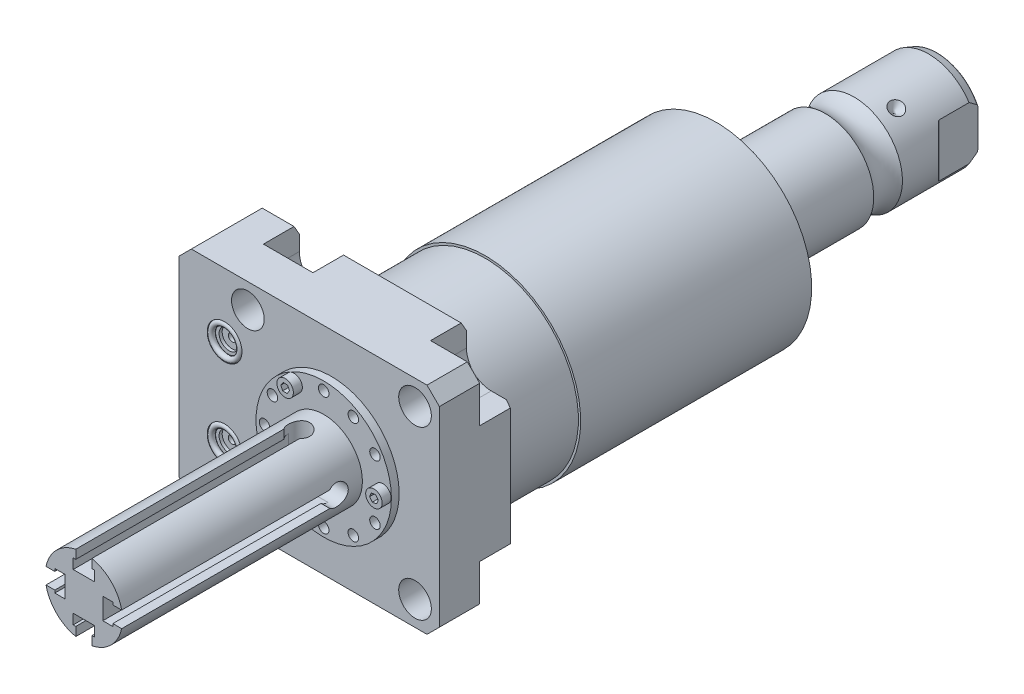
from build123d import *

# Parameters (mm, degrees)
SKETCH1_W                   = 85.4964
SKETCH1_H                   = 70.866
EXTRUDE1_DEPTH              = 25.019
SKETCH2_R                   = 5.3594
CUT_EXTRUDE1_DEPTH          = 27.5209
LPATTERN1_COUNT             = 2
LPATTERN1_PITCH             = 54.864
LPATTERN1_COUNT_DIR2        = 2
LPATTERN1_PITCH_DIR2        = 54.864
CUT_EXTRUDE2_DEPTH          = 11.7856
SKETCH6_R                   = 5.7023
CUT_EXTRUDE3_DEPTH          = 1.4478
SKETCH7_R                   = 3.2512
CUT_EXTRUDE4_DEPTH          = 1.016
SKETCH8_R                   = 1.2446
CUT_EXTRUDE5_DEPTH          = 11.9888
SKETCH9_R                   = 0.9271
CHAMFER1_SIZE               = 4.064
CHAMFER2_SIZE               = 3.0226
CHAMFER2_SIZE2              = 1.745099
SKETCH14_R                  = 31.3944
EXTRUDE2_DEPTH              = 104.5464
SKETCH15_OUTSIDE_W          = 121.686
SKETCH15_OUTSIDE_H          = 107.056
SKETCH15_OUTSIDE_R          = 30.6578
CUT_EXTRUDE9_DEPTH          = 25.4
CIRPATTERN1_COUNT           = 3
FILLET1_R                   = 0.635
CUT_EXTRUDE12_DEPTH         = 36.433
CUT_EXTRUDE12_DEPTH_BACK    = 36.433
SKETCH28_R                  = 1.7272
CUT_EXTRUDE13_DEPTH         = 2.54
SKETCH29_R                  = 2.7051
EXTRUDE3_DEPTH              = 2.9464
CUT_EXTRUDE14_DEPTH         = 2.032
CUT_EXTRUDE15_DEPTH         = 6.477
SKETCH32_W                  = 6.985
SKETCH32_H                  = 70.612
CUT_EXTRUDE16_DEPTH         = 3.302
CIRPATTERN2_COUNT           = 2
CIRPATTERN2_ANGLE           = 90
CIRPATTERN2_COPY_1_DEPTH    = 6.477
CIRPATTERN2_COPY_2_SKETCH_W = 6.985
CIRPATTERN2_COPY_2_SKETCH_H = 70.612
CIRPATTERN2_COPY_2_DEPTH    = 3.302


with BuildPart() as part:
    # Sketch1 → Extrude1 (new body)
    with BuildSketch(Plane.XY):
        with Locations((-7.3152, 0)):
            Rectangle(SKETCH1_W, SKETCH1_H)
    extrude(amount=EXTRUDE1_DEPTH)

    # Sketch2 → Cut-Extrude1 (cut)
    with BuildSketch(Plane(origin=(0, 0, 0), x_dir=(-1, 0, 0), z_dir=(0, 0, -1))):
        with Locations((-27.432, -27.432)):
            Circle(SKETCH2_R)
    cut_extrude1 = extrude(amount=-CUT_EXTRUDE1_DEPTH, mode=Mode.SUBTRACT)

    # LPattern1: Cut-Extrude1 2 × 2
    with Locations(*[(-j * LPATTERN1_PITCH_DIR2, i * LPATTERN1_PITCH, 0) for i in range(LPATTERN1_COUNT) for j in range(LPATTERN1_COUNT_DIR2) if (i, j) != (0, 0)]):
        add(cut_extrude1, mode=Mode.SUBTRACT)

    # Sketch3 → Cut-Extrude2 (cut)
    with BuildSketch(Plane(origin=(0, 0, 0), x_dir=(-1, 0, 0), z_dir=(0, 0, -1))):
        with BuildLine():
            Line((-27.432, -19.304), (-35.433, -19.304))
            Line((-35.433, -19.304), (-35.433, -35.433))
            Line((-35.433, -35.433), (-19.304, -35.433))
            Line((-19.304, -35.433), (-19.304, -27.432))
            ThreePointArc((-19.304, -27.432), (-21.684636, -21.684636), (-27.432, -19.304))
        make_face()
        with BuildLine():
            Line((-35.433, 19.304), (-35.433, 35.433))
            Line((-35.433, 35.433), (-19.304, 35.433))
            Line((-19.304, 35.433), (-19.304, 27.432))
            ThreePointArc((-19.304, 27.432), (-21.684636, 21.684636), (-27.432, 19.304))
            Line((-27.432, 19.304), (-35.433, 19.304))
        make_face()
        with BuildLine():
            Line((19.304, 35.433), (19.304, 27.432))
            ThreePointArc((19.304, 27.432), (27.432, 19.304), (35.56, 27.432))
            Line((35.56, 27.432), (35.56, 35.433))
            Line((35.56, 35.433), (19.304, 35.433))
        make_face()
        with BuildLine():
            Line((35.56, -35.433), (19.304, -35.433))
            Line((19.304, -35.433), (19.304, -27.432))
            ThreePointArc((19.304, -27.432), (27.432, -19.304), (35.56, -27.432))
            Line((35.56, -27.432), (35.56, -35.433))
        make_face()
    extrude(amount=-CUT_EXTRUDE2_DEPTH, mode=Mode.SUBTRACT)

    # S2D0007 → Cut-Revolve1 (revolve, cut)
    with BuildSketch(Plane(origin=(-55.5498, -13.0048, 12.5222), x_dir=(0, 1, 0), z_dir=(0, 0, 1)), mode=Mode.PRIVATE) as cut_revolve1_sk:
        Polygon((0, -5.4864), (10.4775, -5.4864), (10.4775, -5.7404), (6.1849, -5.7404), (5.642307, -8.2931), (4.9784, -8.957007), (4.9784, -19.7104), (0, -19.7104), align=None)
    cut_revolve1 = revolve(cut_revolve1_sk.sketch.rotate(Axis((-35.077219, -13.0048, 12.5222), (-1, 0, 0)), 90), axis=Axis((-35.077219, -13.0048, 12.5222), (-1, 0, 0)), mode=Mode.SUBTRACT)  # turned: the seam where the file's is

    # Mirror1: Cut-Revolve1 across plane
    add(cut_revolve1.mirror(Plane.ZX), mode=Mode.SUBTRACT)

    # Sketch6 → Cut-Extrude3 (cut)
    with BuildSketch(Plane.XY.offset(25.019)):
        with Locations((-35.0774, -14.5288)):
            Circle(SKETCH6_R)
        with Locations((-35.0774, 14.5288)):
            Circle(SKETCH6_R)
    extrude(amount=-CUT_EXTRUDE3_DEPTH, mode=Mode.SUBTRACT)

    # Sketch7 → Cut-Extrude4 (cut)
    with BuildSketch(Plane.XY.offset(23.5712)):
        with Locations((-35.0774, 14.5288)):
            Circle(SKETCH7_R)
        with Locations((-35.0774, -14.5288)):
            Circle(SKETCH7_R)
    extrude(amount=-CUT_EXTRUDE4_DEPTH, mode=Mode.SUBTRACT)

    # Sketch8 → Cut-Extrude5 (cut)
    with BuildSketch(Plane.XY.offset(22.5552)):
        with Locations((-35.0774, 14.5288)):
            Circle(SKETCH8_R)
        with Locations((-35.0774, -14.5288)):
            Circle(SKETCH8_R)
    extrude(amount=-CUT_EXTRUDE5_DEPTH, mode=Mode.SUBTRACT)

    # Chamfer1
    chamfer1_edges = [part.edges().sort_by_distance(p)[0] for p in [
        (-50.0634, 35.433, 12.5095),
        (35.433, 35.433, 18.4023),
        (35.433, -35.433, 18.4023),
        (-50.0634, -35.433, 12.5095),
    ]]
    chamfer(chamfer1_edges, length=CHAMFER1_SIZE)

    # Chamfer2
    chamfer2_edges = [part.edges().sort_by_distance(p)[0] for p in [
        (-40.7797, -35.433, 0),
        (35.433, 0, 0),
        (0, 35.433, 0),
        (-40.7797, 35.433, 0),
        (0, -35.433, 0),
    ]]
    chamfer2_side = [part.faces().sort_by_distance(p)[0] for p in [
        (-8.721449, 0, 0),
    ]]
    chamfer(chamfer2_edges, length=CHAMFER2_SIZE, length2=CHAMFER2_SIZE2, reference=chamfer2_side[0])

    # Sketch14 → Extrude2 (add)
    with BuildSketch(Plane(origin=(0, 0, 0), x_dir=(-1, 0, 0), z_dir=(0, 0, -1))):
        with Locations(Location((0, 0, 0), (0, 0, 140.520961))):  # turned: the seam where the file's is
            Circle(SKETCH14_R)
    extrude(amount=EXTRUDE2_DEPTH)

    # Sketch15 outside → Cut-Extrude9 (cut)
    with BuildSketch(Plane(origin=(0, 0, 0), x_dir=(-1, 0, 0), z_dir=(0, 0, -1))):
        with Locations((7.315, 0)):
            Rectangle(SKETCH15_OUTSIDE_W, SKETCH15_OUTSIDE_H)
        Circle(SKETCH15_OUTSIDE_R, mode=Mode.SUBTRACT)
    extrude(amount=CUT_EXTRUDE9_DEPTH, mode=Mode.SUBTRACT)

    # Sketch16 → Cut-Revolve3 (revolve, cut)
    with BuildSketch(Plane(origin=(0, 0, 0), x_dir=(0, 0, 1), z_dir=(1, 0, 0)), mode=Mode.PRIVATE) as cut_revolve3_sk:
        Polygon((-104.5464, 19.05), (-101.238728, 31.3944), (-104.5464, 31.3944), align=None)
    revolve(cut_revolve3_sk.sketch.rotate(Axis((0, 0, -96.582204), (0, 0, 1)), 270), axis=Axis((0, 0, -96.582204), (0, 0, 1)), mode=Mode.SUBTRACT)  # turned: the seam where the file's is

    # Sketch17 → Revolve3 (revolve)
    with BuildSketch(Plane(origin=(0, 0, 0), x_dir=(0, 0, 1), z_dir=(1, 0, 0)), mode=Mode.PRIVATE) as revolve3_sk:
        with BuildLine():
            Line((-104.5464, 0), (-104.5464, 15.875))
            Line((-104.5464, 15.875), (-137.126506, 15.875))
            ThreePointArc((-137.126506, 15.875), (-141.8336, 14.3256), (-146.540694, 15.875))
            Line((-146.540694, 15.875), (-171.0182, 15.875))
            Line((-171.0182, 15.875), (-173.9392, 14.811843))
            Line((-173.9392, 14.811843), (-173.9392, 0))
            Line((-173.9392, 0), (-104.5464, 0))
        make_face()
    revolve(revolve3_sk.sketch.rotate(Axis((0, 0, -180.9369), (0, 0, 1)), 270), axis=Axis((0, 0, -180.9369), (0, 0, 1)))  # turned: the seam where the file's is

    # Sketch22 → Cut-Revolve4 (revolve, cut)
    with BuildSketch(Plane(origin=(0, 0, 0), x_dir=(1, 0, 0), z_dir=(0, 1, 0)), mode=Mode.PRIVATE) as cut_revolve4_sk:
        Polygon((-15.875, 154.9146), (-15.875, 152.5016), (-13.462, 152.5016), align=None)
    cut_revolve4 = revolve(cut_revolve4_sk.sketch.rotate(Axis((-21.668803, 0, -152.5016), (1, 0, 0)), 180), axis=Axis((-21.668803, 0, -152.5016), (1, 0, 0)), mode=Mode.SUBTRACT)  # turned: the seam where the file's is

    # CirPattern1: Cut-Revolve4 ×3 about axis
    cirpattern1_axis = Axis((0, 0, -180.9369), (0, 0, -1))
    for i in range(1, CIRPATTERN1_COUNT):
        add(cut_revolve4.rotate(cirpattern1_axis, i * 360 / CIRPATTERN1_COUNT), mode=Mode.SUBTRACT)

    # Fillet1
    fillet1_edges = [part.edges().sort_by_distance(p)[0] for p in [
        (14.811843, 0, -173.9392),
    ]]
    fillet(fillet1_edges, radius=FILLET1_R)

    # Sketch24 → Hole1 (revolve, cut)
    with BuildSketch(Plane(origin=(0, 0, -173.9392), x_dir=(0, 1, 0), z_dir=(1, 0, 0))):
        Polygon((0, 0), (0, 25.4), (6.9342, 21.233512), (6.9342, 0), align=None)
    revolve(axis=Axis((0, 0, -178.1834), (0, 0, 1)), mode=Mode.SUBTRACT)

    # Sketch26 → Cut-Extrude12 (cut, two sides)
    with BuildSketch(Plane(origin=(0, 0, 0), x_dir=(1, 0, 0), z_dir=(0, 1, 0))) as cut_extrude12_sk:
        with BuildLine():
            Line((-13.2842, 173.9392), (-13.2842, 161.2392))
            ThreePointArc((-13.2842, 161.2392), (-13.342204, 160.947595), (-13.507385, 160.700385))
            Line((-13.507385, 160.700385), (-15.875, 158.332769))
            Line((-15.875, 158.332769), (-15.875, 173.9392))
            Line((-15.875, 173.9392), (-13.2842, 173.9392))
        make_face()
        with BuildLine():
            Line((15.875, 173.9392), (13.2842, 173.9392))
            Line((13.2842, 173.9392), (13.2842, 161.2392))
            ThreePointArc((13.2842, 161.2392), (13.342204, 160.947595), (13.507385, 160.700385))
            Line((13.507385, 160.700385), (15.875, 158.332769))
            Line((15.875, 158.332769), (15.875, 173.9392))
        make_face()
    extrude(amount=CUT_EXTRUDE12_DEPTH, mode=Mode.SUBTRACT)
    extrude(cut_extrude12_sk.sketch, amount=-CUT_EXTRUDE12_DEPTH_BACK, mode=Mode.SUBTRACT)

    # Sketch27 → Revolve4 (revolve)
    with BuildSketch(Plane(origin=(0, 0, 0), x_dir=(1, 0, 0), z_dir=(0, 1, 0)), mode=Mode.PRIVATE) as revolve4_sk:
        Polygon((22.225, -25.019), (0, -25.019), (0, -106.299), (12.7, -106.299), (12.7, -27.559), (22.225, -27.559), align=None)
    revolve(revolve4_sk.sketch.rotate(Axis((0, 0, 991.574937), (0, 0, -1)), 180), axis=Axis((0, 0, 991.574937), (0, 0, -1)))  # turned: the seam where the file's is

    # Sketch28 → Cut-Extrude13 (cut)
    with BuildSketch(Plane.XY.offset(27.559)):
        with Locations((19.431, 0)):
            Circle(SKETCH28_R)
        with Locations((16.82774, 9.7155)):
            Circle(SKETCH28_R)
        with Locations((9.7155, 16.82774)):
            Circle(SKETCH28_R)
        with Locations((0, 19.431)):
            Circle(SKETCH28_R)
        with Locations(Location((-9.7155, 16.82774, 0), (0, 0, 180))):  # turned: the seam where the file's is
            Circle(SKETCH28_R)
        with Locations(Location((-16.82774, 9.7155, 0), (0, 0, 180))):  # turned: the seam where the file's is
            Circle(SKETCH28_R)
        with Locations(Location((-19.431, 0, 0), (0, 0, 180))):  # turned: the seam where the file's is
            Circle(SKETCH28_R)
        with Locations((-16.82774, -9.7155)):
            Circle(SKETCH28_R)
        with Locations((-9.7155, -16.82774)):
            Circle(SKETCH28_R)
        with Locations(Location((0, -19.431, 0), (0, 0, 180))):  # turned: the seam where the file's is
            Circle(SKETCH28_R)
        with Locations(Location((9.7155, -16.82774, 0), (0, 0, 180))):  # turned: the seam where the file's is
            Circle(SKETCH28_R)
        with Locations(Location((16.82774, -9.7155, 0), (0, 0, 180))):  # turned: the seam where the file's is
            Circle(SKETCH28_R)
    extrude(amount=-CUT_EXTRUDE13_DEPTH, mode=Mode.SUBTRACT)

    # Sketch29 → Extrude3 (add)
    with BuildSketch(Plane.XY.offset(27.559)):
        with Locations((19.431, 0)):
            Circle(SKETCH29_R)
        with Locations((-9.7155, 16.82774)):
            Circle(SKETCH29_R)
        with Locations((-9.7155, -16.82774)):
            Circle(SKETCH29_R)
    extrude(amount=EXTRUDE3_DEPTH)

    # Sketch30 → Cut-Extrude14 (cut)
    with BuildSketch(Plane.XY.offset(30.5054)):
        Polygon((-9.061083, 15.548244), (-8.280215, 16.754734), (-8.934633, 18.03423), (-10.369917, 18.107236), (-11.150785, 16.900746), (-10.496367, 15.62125), align=None)
        Polygon((-9.133395, -18.141713), (-8.286513, -16.980608), (-8.868618, -15.666635), (-10.297605, -15.513766), (-11.144487, -16.674871), (-10.562382, -17.988844), align=None)
        Polygon((20.335319, -1.116951), (20.850467, 0.224688), (19.946148, 1.341639), (18.526681, 1.116951), (18.011533, -0.224688), (18.915852, -1.341639), align=None)
    extrude(amount=-CUT_EXTRUDE14_DEPTH, mode=Mode.SUBTRACT)

    # Sketch31 → Cut-Extrude15 (cut)
    with BuildSketch(Plane(origin=(0, 12.7, 66.929), x_dir=(-1, 0, 0), z_dir=(0, 1, 0))):
        with BuildLine():
            Line((-2.6416, 39.37), (-2.6416, -28.957376))
            ThreePointArc((-2.6416, -28.957376), (0, -34.7345), (2.6416, -28.957376))
            Line((2.6416, -28.957376), (2.6416, 39.37))
            Line((2.6416, 39.37), (-2.6416, 39.37))
        make_face()
    cut_extrude15 = extrude(amount=-CUT_EXTRUDE15_DEPTH, mode=Mode.SUBTRACT)

    # Sketch32 → Cut-Extrude16 (cut)
    with BuildSketch(Plane(origin=(0, 6.223, 0), x_dir=(1, 0, 0), z_dir=(0, 1, 0))):
        with Locations((0, -70.993)):
            Rectangle(SKETCH32_W, SKETCH32_H)
    cut_extrude16 = extrude(amount=CUT_EXTRUDE16_DEPTH, mode=Mode.SUBTRACT)

    # Mirror3: Cut-Extrude15, Cut-Extrude16 across plane
    add(cut_extrude15.mirror(Plane.ZX), mode=Mode.SUBTRACT)
    add(cut_extrude16.mirror(Plane.ZX), mode=Mode.SUBTRACT)

    # CirPattern2: Cut-Extrude15, Cut-Extrude16 ×2 about axis
    cirpattern2_axis = Axis((0, 0, 0), (0, 0, 1))
    add([cut_extrude15.rotate(cirpattern2_axis, i * CIRPATTERN2_ANGLE / (CIRPATTERN2_COUNT - 1)) for i in range(1, CIRPATTERN2_COUNT)], mode=Mode.SUBTRACT)
    add([cut_extrude16.rotate(cirpattern2_axis, i * CIRPATTERN2_ANGLE / (CIRPATTERN2_COUNT - 1)) for i in range(1, CIRPATTERN2_COUNT)], mode=Mode.SUBTRACT)

    # CirPattern2 copy 1 sketch → CirPattern2 copy 1 (cut)
    with BuildSketch(Plane(origin=(12.7, 0, 66.929), x_dir=(0, -1, 0), z_dir=(1, 0, 0))):
        with BuildLine():
            Line((-2.6416, -39.37), (-2.6416, 28.957376))
            ThreePointArc((-2.6416, 28.957376), (0, 34.7345), (2.6416, 28.957376))
            Line((2.6416, 28.957376), (2.6416, -39.37))
            Line((2.6416, -39.37), (-2.6416, -39.37))
        make_face()
    extrude(amount=-CIRPATTERN2_COPY_1_DEPTH, mode=Mode.SUBTRACT)

    # CirPattern2 copy 2 sketch → CirPattern2 copy 2 (cut)
    with BuildSketch(Plane.YZ.offset(6.223)):
        with Locations((0, 70.993)):
            Rectangle(CIRPATTERN2_COPY_2_SKETCH_W, CIRPATTERN2_COPY_2_SKETCH_H)
    extrude(amount=CIRPATTERN2_COPY_2_DEPTH, mode=Mode.SUBTRACT)


with BuildPart() as body_2:
    # Sketch9 → Revolve1 (revolve)
    with BuildSketch(Plane(origin=(-41.656, -14.5288, 23.5712), x_dir=(1, 0, 0), z_dir=(0, 1, 0))):
        with Locations((11.3538, -0.9271)):
            Circle(SKETCH9_R)
    revolve(axis=Axis((-35.0774, -14.5288, 25.51811), (0, 0, -1)))


with BuildPart() as body_3:
    # Mirror2: mirrored copy
    add(body_2.part.mirror(Plane.ZX))


solid = Compound([part.part, body_2.part, body_3.part])
